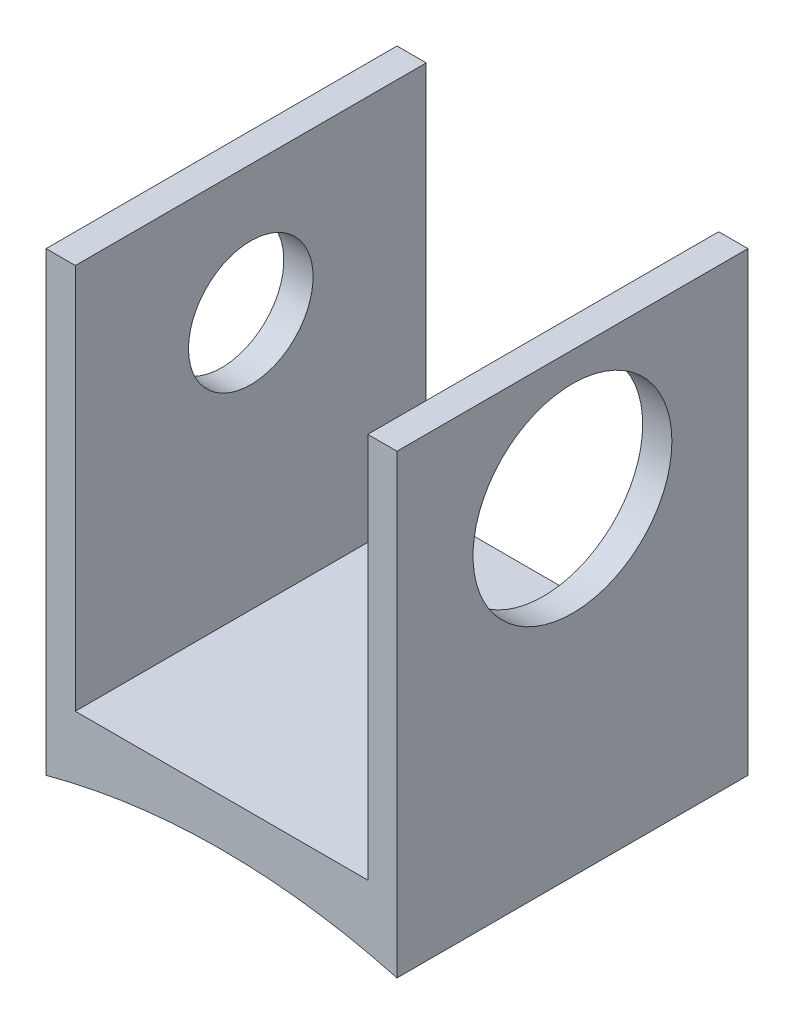
from build123d import *

# Parameters (mm, degrees)
BOSS_EXTRUDE1_DEPTH       = 7.62
F_6_32_TAPPED_HOLE1_D     = 2.7051
F_6_32_TAPPED_HOLE1_DEPTH = 0.635
CUT_EXTRUDE1_REACH        = 9.62
SKETCH6_R                 = 2.159
CUT_EXTRUDE2_DEPTH        = 8.62


with BuildPart() as part:
    # Sketch1 → Boss-Extrude1 (new body)
    with BuildSketch(Plane.XY):
        Polygon((-3.353873239, 7.61418662), (-3.353873239, -2.29181338), (4.266126761, -2.29181338), (4.266126761, 7.61418662), (3.631126761, 7.61418662), (3.631126761, -0.76781338), (-2.718873239, -0.76781338), (-2.718873239, 7.61418662), align=None)
    extrude(amount=BOSS_EXTRUDE1_DEPTH)

    # #6-32 Tapped Hole1
    with Locations(Plane.ZY.offset(3.353873239)):
        with Locations((3.81, 4.82018662)):
            Hole(F_6_32_TAPPED_HOLE1_D / 2, depth=F_6_32_TAPPED_HOLE1_DEPTH)

    # Sketch6 → Cut-Extrude1 (cut, up to next)
    with BuildSketch(Plane(origin=(4.266126761, 0, 0), x_dir=(0, 0, -1), z_dir=(1, 0, 0)), mode=Mode.PRIVATE) as cut_extrude1_sk1:
        with Locations((-3.81, 4.82018662)):
            Circle(SKETCH6_R)
    cut_extrude1_tool1 = extrude(cut_extrude1_sk1.sketch, amount=-CUT_EXTRUDE1_REACH, mode=Mode.PRIVATE) & part.part
    add(cut_extrude1_tool1.solids().sort_by_distance((4.266127, 4.820187, 3.81))[0], mode=Mode.SUBTRACT)

    # Sketch16 → Cut-Extrude2 (cut, through all)
    with BuildSketch(Plane(origin=(0, 0, 0), x_dir=(-1, 0, 0), z_dir=(0, 0, -1))):
        with BuildLine():
            Line((3.353873239, -2.29181338), (-4.266126761, -2.29181338))
            ThreePointArc((-4.266126761, -2.29181338), (-0.456126761, -1.781504099), (3.353873239, -2.29181338))
        make_face()
    extrude(amount=-CUT_EXTRUDE2_DEPTH, mode=Mode.SUBTRACT)


solid = part.part
